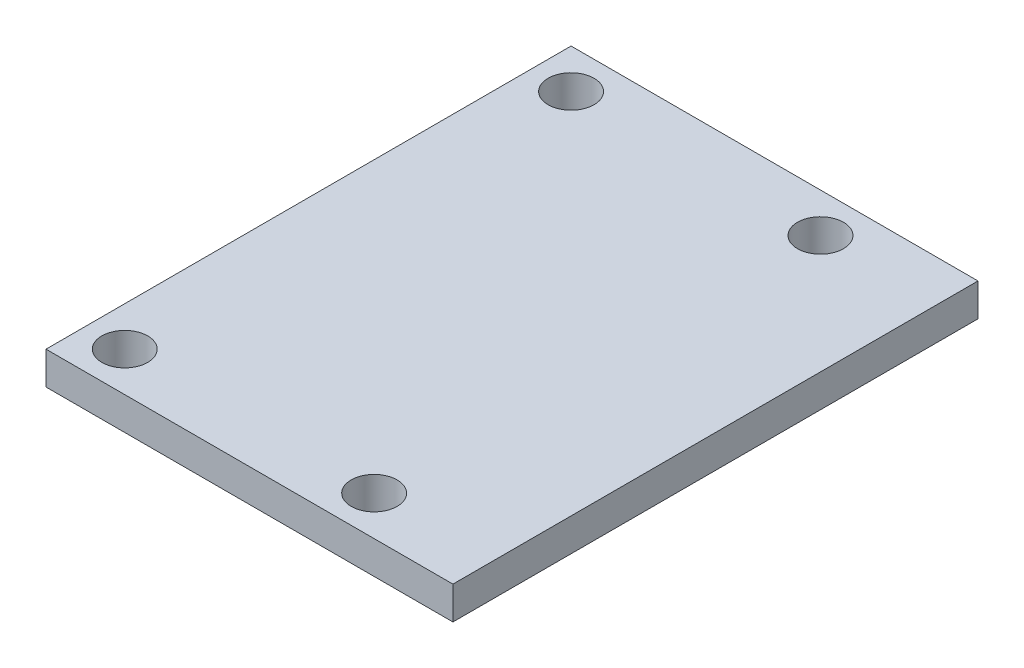
from build123d import *

# Parameters (mm, degrees)
BOSS_EXTRUDE1_DEPTH = 40
CUT_EXTRUDE2_REACH  = 4.5
SKETCH3_R           = 1.75


with BuildPart() as part:
    # Sketch1 → Boss-Extrude1 (new body)
    with BuildSketch(Plane.XY):
        Polygon((0, 0), (-31, 0), (-31, 2.5), (-6, 2.5), (0, 2.5), align=None)
    extrude(amount=BOSS_EXTRUDE1_DEPTH)

    # Sketch3 → Cut-Extrude2 (cut, up to next)
    with BuildSketch(Plane(origin=(0, 2.5, 0), x_dir=(1, 0, 0), z_dir=(0, 1, 0)), mode=Mode.PRIVATE) as cut_extrude2_sk1:
        with Locations((-9, -3)):
            Circle(SKETCH3_R)
    cut_extrude2_tool1 = extrude(cut_extrude2_sk1.sketch, amount=-CUT_EXTRUDE2_REACH, mode=Mode.PRIVATE) & part.part
    add(cut_extrude2_tool1.solids().sort_by_distance((-9, 2.5, 3))[0], mode=Mode.SUBTRACT)
    # Sketch3 → Cut-Extrude2 (cut, up to next)
    with BuildSketch(Plane(origin=(0, 2.5, 0), x_dir=(1, 0, 0), z_dir=(0, 1, 0)), mode=Mode.PRIVATE) as cut_extrude2_sk2:
        with Locations((-28, -3)):
            Circle(SKETCH3_R)
    cut_extrude2_tool2 = extrude(cut_extrude2_sk2.sketch, amount=-CUT_EXTRUDE2_REACH, mode=Mode.PRIVATE) & part.part
    add(cut_extrude2_tool2.solids().sort_by_distance((-28, 2.5, 3))[0], mode=Mode.SUBTRACT)
    # Sketch3 → Cut-Extrude2 (cut, up to next)
    with BuildSketch(Plane(origin=(0, 2.5, 0), x_dir=(1, 0, 0), z_dir=(0, 1, 0)), mode=Mode.PRIVATE) as cut_extrude2_sk3:
        with Locations((-28, -37)):
            Circle(SKETCH3_R)
    cut_extrude2_tool3 = extrude(cut_extrude2_sk3.sketch, amount=-CUT_EXTRUDE2_REACH, mode=Mode.PRIVATE) & part.part
    add(cut_extrude2_tool3.solids().sort_by_distance((-28, 2.5, 37))[0], mode=Mode.SUBTRACT)
    # Sketch3 → Cut-Extrude2 (cut, up to next)
    with BuildSketch(Plane(origin=(0, 2.5, 0), x_dir=(1, 0, 0), z_dir=(0, 1, 0)), mode=Mode.PRIVATE) as cut_extrude2_sk4:
        with Locations((-9, -37)):
            Circle(SKETCH3_R)
    cut_extrude2_tool4 = extrude(cut_extrude2_sk4.sketch, amount=-CUT_EXTRUDE2_REACH, mode=Mode.PRIVATE) & part.part
    add(cut_extrude2_tool4.solids().sort_by_distance((-9, 2.5, 37))[0], mode=Mode.SUBTRACT)


solid = part.part
